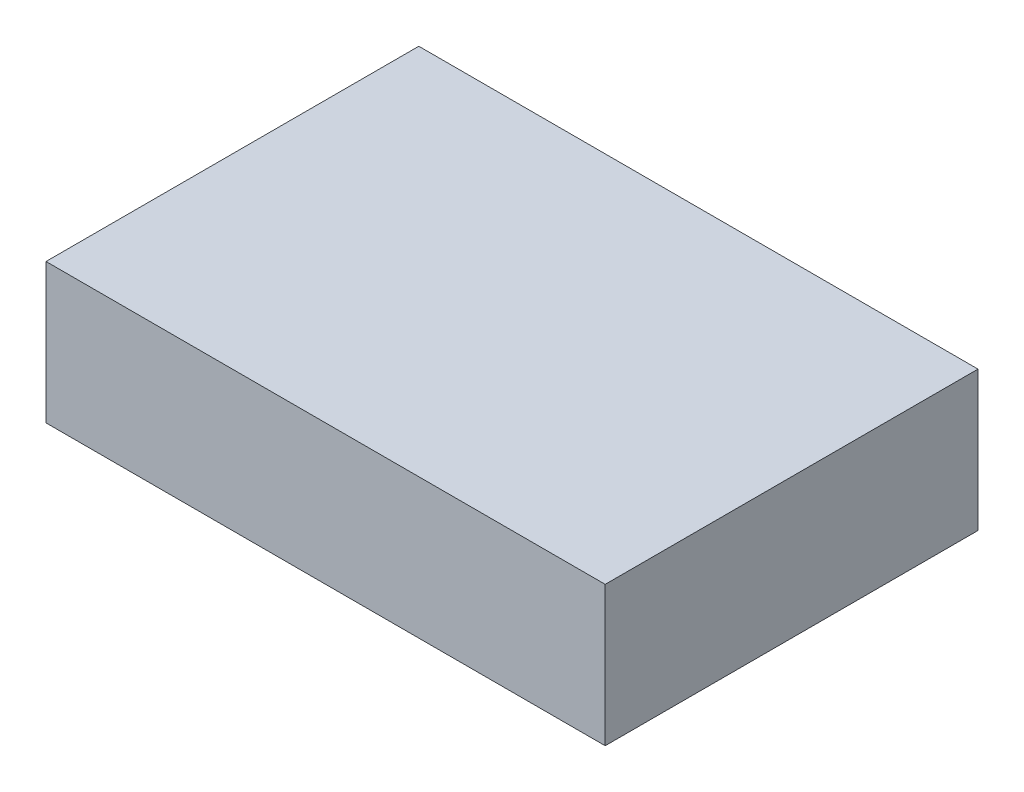
from build123d import *

# Parameters (mm, degrees)
SKETCH1_W           = 120
SKETCH1_H           = 80
BOSS_EXTRUDE1_DEPTH = 30


with BuildPart() as part:
    # Sketch1 → Boss-Extrude1 (new body)
    with BuildSketch(Plane(origin=(0, 0, 0), x_dir=(1, 0, 0), z_dir=(0, 1, 0))):
        Rectangle(SKETCH1_W, SKETCH1_H)
    extrude(amount=BOSS_EXTRUDE1_DEPTH)


solid = part.part
